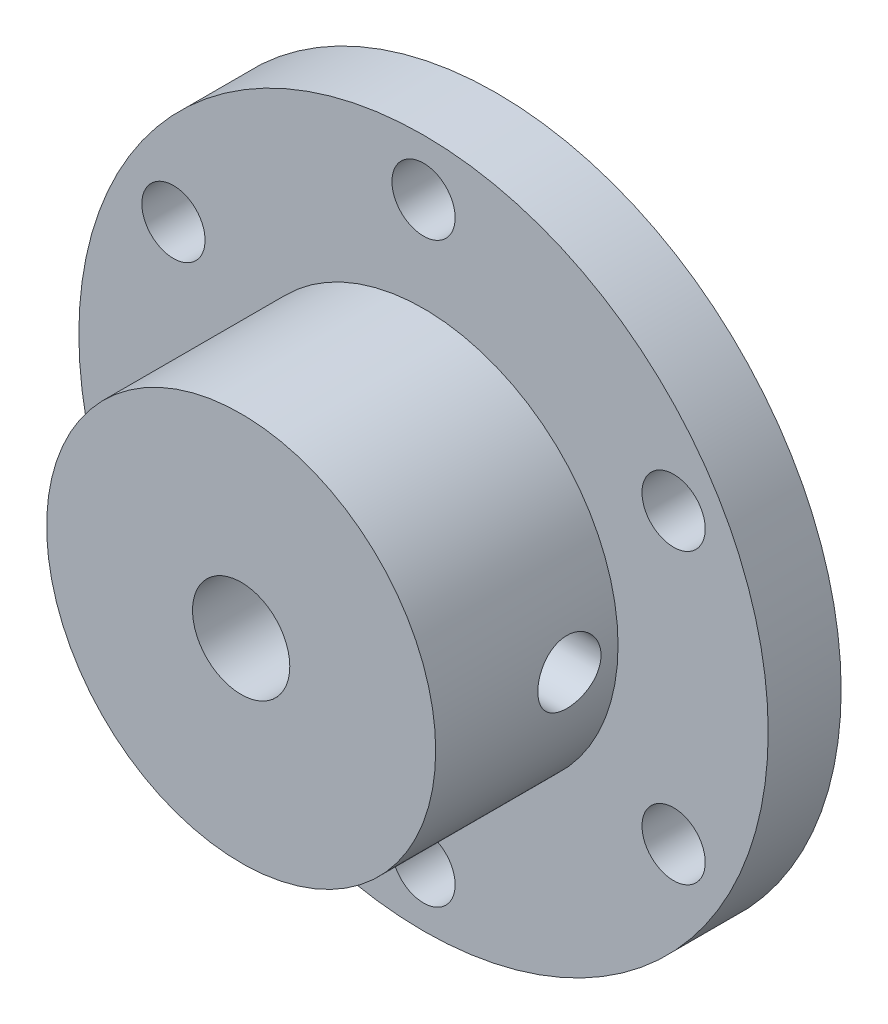
from build123d import *

# Parameters (mm, degrees)
SKETCH_1_R               = 28.35
EXTRUDE_1_DEPTH          = 6
SKETCH_2_R               = 16
EXTRUDE_2_DEPTH          = 15
SKETCH_7_R               = 11
EXTRUDE_3_DEPTH          = 5
SKETCH_3_R               = 4
CUT_EXTRUDE_1_DEPTH      = 48.785405722
CUT_EXTRUDE_2_REACH      = 44.807
SKETCH_4_R               = 2.6
PATTERN_CIRCULAR_1_COUNT = 6
CUT_EXTRUDE_3_REACH      = 58.671
SKETCH_6_R               = 2.6


with BuildPart() as part:
    # 草圖1 → 填料-伸長1 (new body)
    with BuildSketch(Plane.XY):
        Circle(SKETCH_1_R)
    extrude(amount=EXTRUDE_1_DEPTH)

    # 草圖2 → 填料-伸長2 (add)
    with BuildSketch(Plane.XY.offset(6)):
        Circle(SKETCH_2_R)
    extrude(amount=EXTRUDE_2_DEPTH)

    # 草圖7 → 填料-伸長3 (add)
    with BuildSketch(Plane(origin=(0, 0, 0), x_dir=(-1, 0, 0), z_dir=(0, 0, -1))):
        Circle(SKETCH_7_R)
    extrude(amount=EXTRUDE_3_DEPTH)

    # 草圖3 → 除料-伸長1 (cut, through all)
    with BuildSketch(Plane.XY.offset(21)):
        Circle(SKETCH_3_R)
    extrude(amount=-CUT_EXTRUDE_1_DEPTH, mode=Mode.SUBTRACT)

    # 草圖4 → 除料-伸長2 (cut, up to next)
    with BuildSketch(Plane.XY.offset(6), mode=Mode.PRIVATE) as cut_extrude_2_sk1:
        with Locations((0, 23.75)):
            Circle(SKETCH_4_R)
    cut_extrude_2_tool1 = extrude(cut_extrude_2_sk1.sketch, amount=-CUT_EXTRUDE_2_REACH, mode=Mode.PRIVATE) & part.part
    cut_extrude_2 = cut_extrude_2_tool1.solids().sort_by_distance((0, 23.75, 6))[0]
    add(cut_extrude_2, mode=Mode.SUBTRACT)

    # 環狀複製排列1: 除料-伸長2 ×6 about axis
    pattern_circular_1_axis = Axis((0, 0, 6), (0, 0, 1))
    for i in range(1, PATTERN_CIRCULAR_1_COUNT):
        add(cut_extrude_2.rotate(pattern_circular_1_axis, i * 360 / PATTERN_CIRCULAR_1_COUNT), mode=Mode.SUBTRACT)

    # 草圖6 → 除料-伸長3 (cut, up to next)
    with BuildSketch(Plane(origin=(16, 0, 0), x_dir=(0, 0, -1), z_dir=(1, 0, 0)), mode=Mode.PRIVATE) as cut_extrude_3_sk1:
        with Locations((-10, 0)):
            Circle(SKETCH_6_R)
    cut_extrude_3_tool1 = extrude(cut_extrude_3_sk1.sketch, amount=-CUT_EXTRUDE_3_REACH, mode=Mode.PRIVATE) & part.part
    add(cut_extrude_3_tool1.solids().sort_by_distance((16, 0, 10))[0], mode=Mode.SUBTRACT)


solid = part.part
